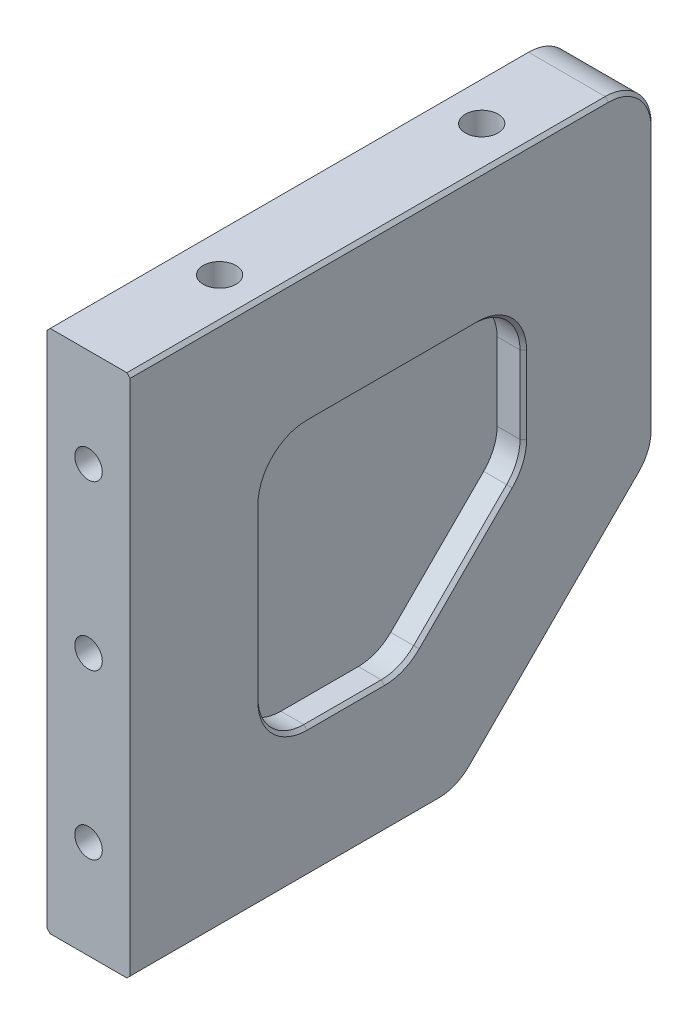
from build123d import *

# Parameters (mm, degrees)
SKETCH1_W            = 80
SKETCH1_H            = 80
BOSS_EXTRUDE1_DEPTH  = 6.35
CHAMFER1_SIZE        = 30
SKETCH2_R            = 2.5
CUT_EXTRUDE1_DEPTH   = 17
SKETCH3_R            = 2.1
CUT_EXTRUDE2_DEPTH   = 15
CUT_EXTRUDE3_DEPTH   = 4
FILLET1_R            = 7
FILLET1_OF_MIRROR2_R = 7
FILLET2_R            = 7
CHAMFER2_SIZE        = 0.5


with BuildPart() as part:
    # Sketch1 → Boss-Extrude1 (new body, symmetric)
    with BuildSketch(Plane(origin=(0, 0, 0), x_dir=(0, 0, -1), z_dir=(1, 0, 0))):
        Rectangle(SKETCH1_W, SKETCH1_H)
    extrude(amount=BOSS_EXTRUDE1_DEPTH, both=True)

    # Chamfer1
    chamfer1_edges = [part.edges().sort_by_distance(p)[0] for p in [
        (0, -40, -40),
    ]]
    chamfer(chamfer1_edges, length=CHAMFER1_SIZE)

    # Sketch2 → Cut-Extrude1 (cut)
    with BuildSketch(Plane(origin=(0, 40, 0), x_dir=(1, 0, 0), z_dir=(0, 1, 0))):
        with Locations((0, 20)):
            Circle(SKETCH2_R)
        with Locations((0, -20)):
            Circle(SKETCH2_R)
    extrude(amount=-CUT_EXTRUDE1_DEPTH, mode=Mode.SUBTRACT)

    # Sketch3 → Cut-Extrude2 (cut)
    with BuildSketch(Plane.XY.offset(40)):
        with Locations((0, 25)):
            Circle(SKETCH3_R)
        with Locations((0, -25)):
            Circle(SKETCH3_R)
        Circle(SKETCH3_R)
    extrude(amount=-CUT_EXTRUDE2_DEPTH, mode=Mode.SUBTRACT)

    # Sketch4 → Cut-Extrude3 (cut)
    with BuildSketch(Plane(origin=(6.35, 0, 0), x_dir=(0, 0, -1), z_dir=(1, 0, 0))):
        Polygon((-20, -20), (1.715728753, -20), (20, -1.715728753), (20, 20), (-20, 20), align=None)
    cut_extrude3 = extrude(amount=-CUT_EXTRUDE3_DEPTH, mode=Mode.SUBTRACT)

    # Fillet1
    fillet1_edges = [part.edges().sort_by_distance(p)[0] for p in [
        (4.35, -20, 20),
        (4.35, 20, 20),
        (4.35, 20, -20),
        (4.35, -1.715728753, -20),
        (4.35, -20, -1.715728753),
    ]]
    fillet(fillet1_edges, radius=FILLET1_R)

    # Mirror2: Cut-Extrude3 across plane
    add(cut_extrude3.mirror(Plane(origin=(0, 0, 0), x_dir=(0, 0, 1), z_dir=(1, 0, 0))), mode=Mode.SUBTRACT)

    # Fillet1 of Mirror2
    fillet1_of_mirror2_edges = [part.edges().sort_by_distance(p)[0] for p in [
        (-4.35, -20, 20),
        (-4.35, 20, 20),
        (-4.35, 20, -20),
        (-4.35, -1.715728753, -20),
        (-4.35, -20, -1.715728753),
    ]]
    fillet(fillet1_of_mirror2_edges, radius=FILLET1_OF_MIRROR2_R)

    # Fillet2
    fillet2_edges = [part.edges().sort_by_distance(p)[0] for p in [
        (0, -10, -40),
        (0, -40, -10),
        (0, 40, -40),
    ]]
    fillet(fillet2_edges, radius=FILLET2_R)

    # Chamfer2
    chamfer2_edges = [part.edges().sort_by_distance(p)[0] for p in [
        (-6.35, 0, 20),
        (-6.35, -20, 7.091883092),
        (-6.35, -10.857864376, -10.857864376),
        (-6.35, 7.091883092, -20),
        (-6.35, 20, 0),
        (-6.35, -17.949747468, 17.949747468),
        (-6.35, -19.467156728, -1.495017842),
        (-6.35, 17.949747468, -17.949747468),
        (-6.35, 17.949747468, 17.949747468),
        (-6.35, -1.495017842, -19.467156728),
        (6.35, -25, -25),
        (6.35, 12.949747468, -40),
        (6.35, 40, 3.5),
        (6.35, 37.949747468, -37.949747468),
        (6.35, -9.77928909, -39.467156728),
        (6.35, -39.467156728, -9.77928909),
        (-6.35, -25, -25),
        (-6.35, 12.949747468, -40),
        (-6.35, 40, 3.5),
        (-6.35, 37.949747468, -37.949747468),
        (-6.35, -9.77928909, -39.467156728),
        (-6.35, -39.467156728, -9.77928909),
        (6.35, -20, 7.091883092),
        (-6.35, -40, 16.449747468),
        (6.35, 0, 20),
        (6.35, -10.857864376, -10.857864376),
        (6.35, 20, 0),
        (6.35, 7.091883092, -20),
        (6.35, -17.949747468, 17.949747468),
        (6.35, -19.467156728, -1.495017842),
        (6.35, 17.949747468, -17.949747468),
        (6.35, 17.949747468, 17.949747468),
        (6.35, -1.495017842, -19.467156728),
        (6.35, -40, 16.449747468),
    ]]
    chamfer(chamfer2_edges, length=CHAMFER2_SIZE)


solid = part.part
